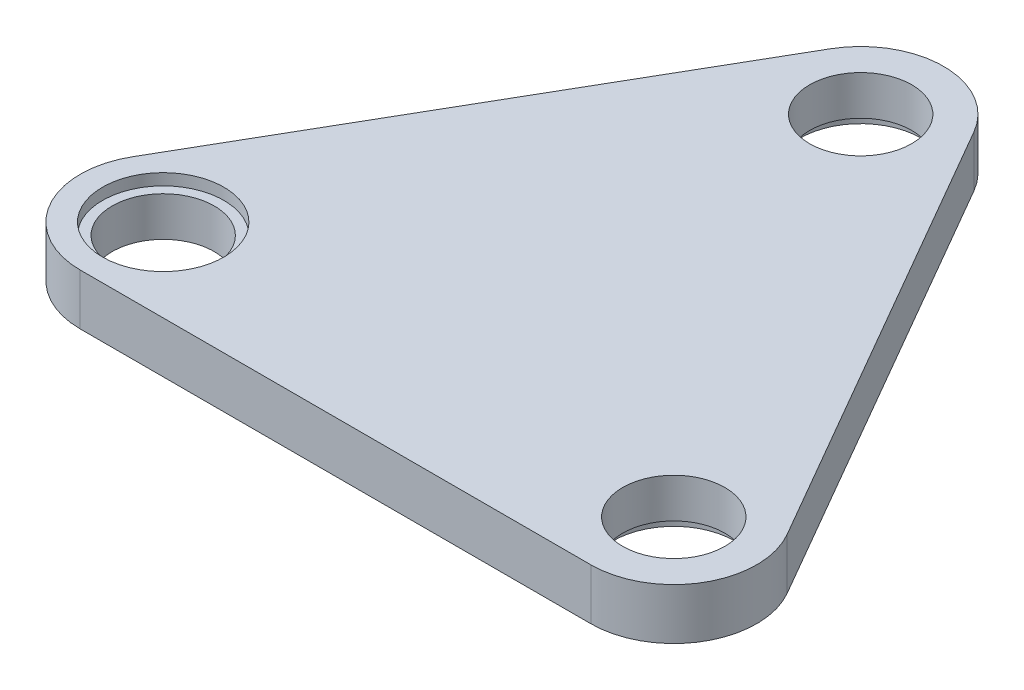
from build123d import *

# Parameters (mm, degrees)
EXTRUDE_1_DEPTH              = 4
HOLE_WIZARD_M5_1_D           = 8
HOLE_WIZARD_M5_1_DEPTH       = 12.4
HOLE_WIZARD_M5_1_CBORE_D     = 9.5
HOLE_WIZARD_M5_1_CBORE_DEPTH = 0.9
HOLE_WIZARD_M5_1_TIP         = 2.403442476
HOLE_WIZARD_M5_2_D           = 8
HOLE_WIZARD_M5_2_DEPTH       = 12.4
HOLE_WIZARD_M5_2_CBORE_D     = 9.5
HOLE_WIZARD_M5_2_CBORE_DEPTH = 0.9
HOLE_WIZARD_M5_2_TIP         = 2.403442476


with BuildPart() as part:
    # 草图2 → 凸台-拉伸1 (new body)
    with BuildSketch(Plane(origin=(0, 0, 0), x_dir=(1, 0, 0), z_dir=(0, 1, 0))):
        with BuildLine():
            Line((20, 21.641016151), (28.741669751, 6.5))
            Line((28.741669751, 6.5), (40, 6.5))
            ThreePointArc((40, 6.5), (43.25, 5.629165125), (45.629165125, 3.25))
            Line((45.629165125, 3.25), (25.629165125, 37.891016151))
            ThreePointArc((25.629165125, 37.891016151), (26.5, 34.641016151), (25.629165125, 31.391016151))
            Line((25.629165125, 31.391016151), (20, 21.641016151))
        make_face()
        with BuildLine():
            Line((28.741669751, 6.5), (11.258330249, 6.5))
            Line((11.258330249, 6.5), (5.629165125, -3.25))
            ThreePointArc((5.629165125, -3.25), (3.25, -5.629165125), (0, -6.5))
            Line((0, -6.5), (40, -6.5))
            ThreePointArc((40, -6.5), (36.75, -5.629165125), (34.370834875, -3.25))
            Line((34.370834875, -3.25), (28.741669751, 6.5))
        make_face()
        with BuildLine():
            Line((40, 6.5), (28.741669751, 6.5))
            Line((28.741669751, 6.5), (34.370834875, -3.25))
            ThreePointArc((34.370834875, -3.25), (36.75, -5.629165125), (40, -6.5))
            ThreePointArc((40, -6.5), (45.629165125, -3.25), (45.629165125, 3.25))
            ThreePointArc((45.629165125, 3.25), (43.25, 5.629165125), (40, 6.5))
        make_face()
        with BuildLine():
            ThreePointArc((-5.629165125, 3.25), (-3.25, 5.629165125), (0, 6.5))
            Line((0, 6.5), (11.258330249, 6.5))
            Line((11.258330249, 6.5), (20, 21.641016151))
            Line((20, 21.641016151), (14.370834875, 31.391016151))
            ThreePointArc((14.370834875, 31.391016151), (13.5, 34.641016151), (14.370834875, 37.891016151))
            Line((14.370834875, 37.891016151), (-5.629165125, 3.25))
        make_face()
        with BuildLine():
            Line((14.370834875, 31.391016151), (20, 21.641016151))
            Line((20, 21.641016151), (25.629165125, 31.391016151))
            ThreePointArc((25.629165125, 31.391016151), (26.5, 34.641016151), (25.629165125, 37.891016151))
            ThreePointArc((25.629165125, 37.891016151), (20, 41.141016151), (14.370834875, 37.891016151))
            ThreePointArc((14.370834875, 37.891016151), (13.5, 34.641016151), (14.370834875, 31.391016151))
        make_face()
        with BuildLine():
            Line((11.258330249, 6.5), (0, 6.5))
            ThreePointArc((0, 6.5), (-3.25, 5.629165125), (-5.629165125, 3.25))
            ThreePointArc((-5.629165125, 3.25), (-5.629165125, -3.25), (0, -6.5))
            ThreePointArc((0, -6.5), (3.25, -5.629165125), (5.629165125, -3.25))
            Line((5.629165125, -3.25), (11.258330249, 6.5))
        make_face()
        Polygon((20, 21.641016151), (11.258330249, 6.5), (28.741669751, 6.5), align=None)
    extrude(amount=EXTRUDE_1_DEPTH)

    # M5 六角头螺栓的柱形沉头孔1
    with Locations(Plane(origin=(0, 4, 0), x_dir=(1, 0, 0), z_dir=(0, 1, 0))):
        with Locations((0, 0)):
            CounterBoreHole(HOLE_WIZARD_M5_1_D / 2, HOLE_WIZARD_M5_1_CBORE_D / 2, HOLE_WIZARD_M5_1_CBORE_DEPTH, depth=HOLE_WIZARD_M5_1_DEPTH)
            with Locations((0, 0, -(HOLE_WIZARD_M5_1_DEPTH + HOLE_WIZARD_M5_1_TIP / 2))):  # 118° drill point
                Cone(0, HOLE_WIZARD_M5_1_D / 2, HOLE_WIZARD_M5_1_TIP, mode=Mode.SUBTRACT)

    # M5 六角头螺栓的柱形沉头孔2
    with Locations(Plane(origin=(0, 0, 0), x_dir=(-1, 0, 0), z_dir=(0, -1, 0))):
        with Locations((-40, 0), (-20, 34.641016151)):
            CounterBoreHole(HOLE_WIZARD_M5_2_D / 2, HOLE_WIZARD_M5_2_CBORE_D / 2, HOLE_WIZARD_M5_2_CBORE_DEPTH, depth=HOLE_WIZARD_M5_2_DEPTH)
            with Locations((0, 0, -(HOLE_WIZARD_M5_2_DEPTH + HOLE_WIZARD_M5_2_TIP / 2))):  # 118° drill point
                Cone(0, HOLE_WIZARD_M5_2_D / 2, HOLE_WIZARD_M5_2_TIP, mode=Mode.SUBTRACT)


solid = part.part
